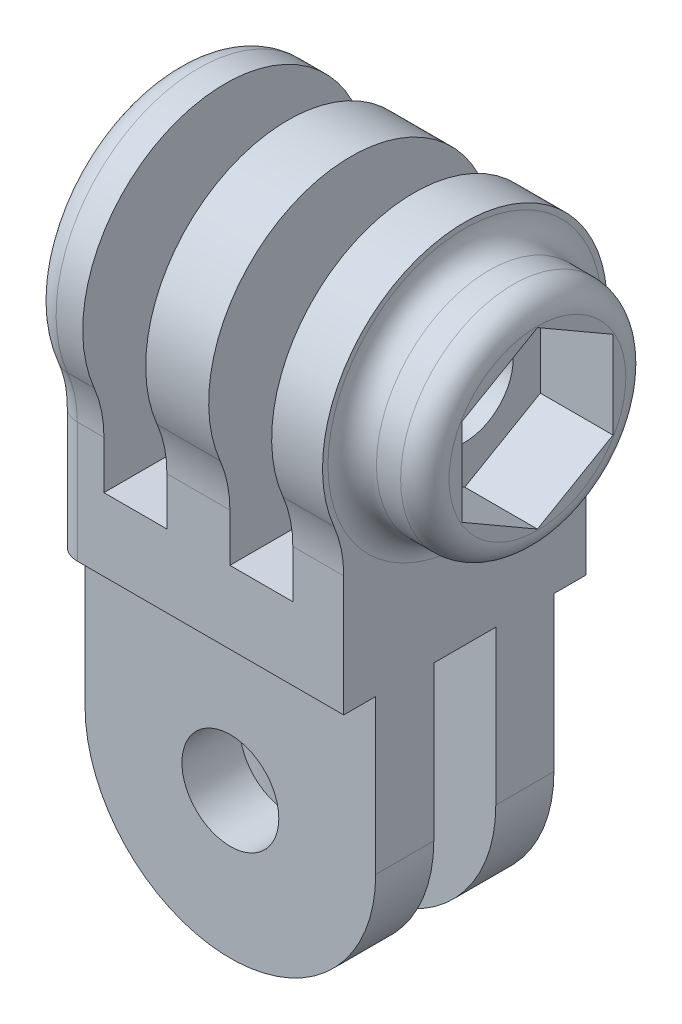
from build123d import *

# Parameters (mm, degrees)
SKETCH1_R               = 2.54
BOSS_EXTRUDE1_DEPTH     = 15.24
CUT_EXTRUDE1_DEPTH      = 28.358513503
SKETCH3_W               = 3.302
SKETCH3_H               = 15.39875
CUT_EXTRUDE2_DEPTH      = 26.630137107
CUT_EXTRUDE2_DEPTH_BACK = 26.630137107
SKETCH5_R               = 5.9055
SKETCH5_R_2             = 2.54
BOSS_EXTRUDE2_DEPTH     = 3.81
CUT_EXTRUDE3_DEPTH      = 3.81
FILLET1_R               = 1.27


with BuildPart() as part:
    # Sketch1 → Boss-Extrude1 (new body)
    with BuildSketch(Plane(origin=(0, 0, 0), x_dir=(0, 0, -1), z_dir=(1, 0, 0))):
        with BuildLine():
            Line((-6.35, 0), (-4.6736, 0))
            Line((-4.6736, 0), (-4.6736, -15.7))
            Line((-4.6736, -15.7), (-1.6256, -15.7))
            Line((-1.6256, -15.7), (-1.6256, 0))
            Line((-1.6256, 0), (1.6256, 0))
            Line((1.6256, 0), (1.6256, -15.7))
            Line((1.6256, -15.7), (4.6736, -15.7))
            Line((4.6736, -15.7), (4.6736, 0))
            Line((4.6736, 0), (6.35, 0))
            Line((6.35, 0), (6.35, 6.319735583))
            ThreePointArc((6.35, 6.319735583), (6.479041034, 7.59337978), (6.86091954, 8.815259453))
            ThreePointArc((6.86091954, 8.815259453), (0, 19.20875), (-6.86091954, 8.815259453))
            ThreePointArc((-6.86091954, 8.815259453), (-6.479041034, 7.59337978), (-6.35, 6.319735583))
            Line((-6.35, 6.319735583), (-6.35, 0))
        make_face()
        with Locations((0, 11.7475)):
            Circle(SKETCH1_R, mode=Mode.SUBTRACT)
    extrude(amount=-BOSS_EXTRUDE1_DEPTH)

    # Sketch2 → Cut-Extrude1 (cut, through all)
    with BuildSketch(Plane.XY.offset(4.6736)):
        with BuildLine():
            ThreePointArc((-5.08, -8.08), (-5.823948776, -6.283948776), (-7.62, -5.54))
            Line((-7.62, -5.54), (-7.62, -10.62))
            ThreePointArc((-7.62, -10.62), (-5.823948776, -9.876051224), (-5.08, -8.08))
        make_face()
        with BuildLine():
            Line((-7.62, -10.62), (-7.62, -5.54))
            ThreePointArc((-7.62, -5.54), (-10.16, -8.08), (-7.62, -10.62))
        make_face()
        with BuildLine():
            ThreePointArc((-7.62, -15.7), (-13.008153673, -13.468153673), (-15.24, -8.08))
            Line((-15.24, -8.08), (-15.24, -15.7))
            Line((-15.24, -15.7), (-7.62, -15.7))
        make_face()
        with BuildLine():
            Line((0, -15.7), (0, -8.08))
            ThreePointArc((0, -8.08), (-2.231846327, -13.468153673), (-7.62, -15.7))
            Line((-7.62, -15.7), (0, -15.7))
        make_face()
    extrude(amount=-CUT_EXTRUDE1_DEPTH, mode=Mode.SUBTRACT)

    # Sketch3 → Cut-Extrude2 (cut, two sides)
    with BuildSketch(Plane.XY) as cut_extrude2_sk:
        with Locations((-4.318, 11.509375)):
            Rectangle(SKETCH3_W, SKETCH3_H)
        with Locations((-10.922, 11.509375)):
            Rectangle(SKETCH3_W, SKETCH3_H)
    extrude(amount=CUT_EXTRUDE2_DEPTH, mode=Mode.SUBTRACT)
    extrude(cut_extrude2_sk.sketch, amount=-CUT_EXTRUDE2_DEPTH_BACK, mode=Mode.SUBTRACT)

    # Sketch5 → Boss-Extrude2 (add)
    with BuildSketch(Plane(origin=(0, 0, 0), x_dir=(0, 0, -1), z_dir=(1, 0, 0))):
        with Locations(Location((0, 11.7475, 0), (0, 0, 180))):
            Circle(SKETCH5_R)
        with Locations((0, 11.7475)):
            Circle(SKETCH5_R_2, mode=Mode.SUBTRACT)
    extrude(amount=BOSS_EXTRUDE2_DEPTH)

    # Sketch6 → Cut-Extrude3 (cut)
    with BuildSketch(Plane(origin=(3.81, 0, 0), x_dir=(0, 0, -1), z_dir=(1, 0, 0))):
        Polygon((0, 16.322885413), (-3.9624, 14.035192707), (-3.9624, 9.459807293), (0, 7.172114587), (3.9624, 9.459807293), (3.9624, 14.035192707), align=None)
    extrude(amount=-CUT_EXTRUDE3_DEPTH, mode=Mode.SUBTRACT)

    # Fillet1
    fillet1_edges = [part.edges().sort_by_distance(p)[0] for p in [
        (0, 11.7475, -5.9055),
        (3.81, 11.7475, -5.9055),
        (-15.24, 3.159867792, -6.35),
        (-15.24, 7.59337978, -6.479041034),
        (-15.24, 3.159867792, 6.35),
        (-15.24, 19.20875, 0),
        (-15.24, 7.59337978, 6.479041034),
    ]]
    fillet(fillet1_edges, radius=FILLET1_R)


solid = part.part
